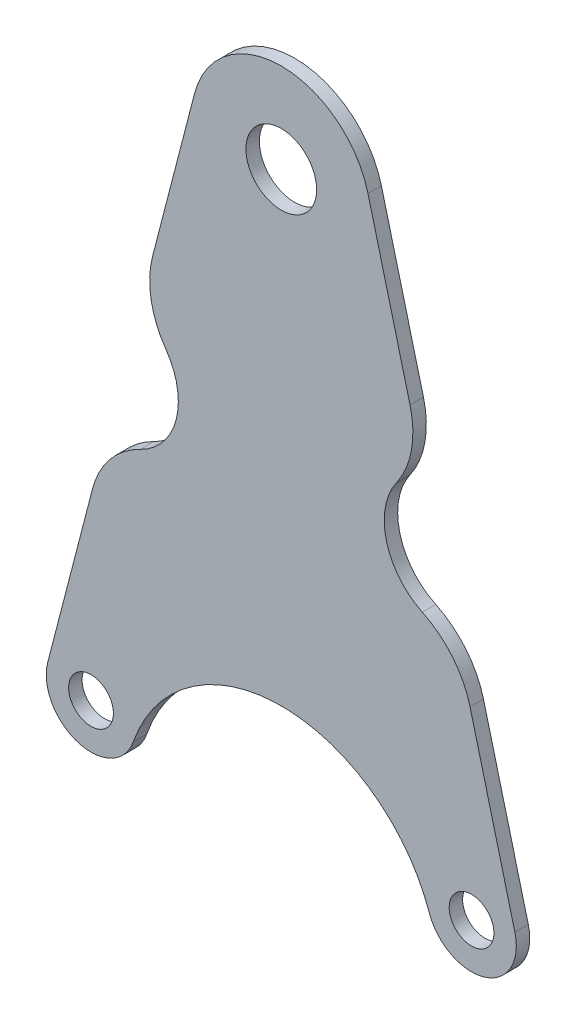
from build123d import *

# Parameters (mm, degrees)
SKETCH_1_R          = 7.9
SKETCH_1_R_2        = 5
EXTRUDE_1_DEPTH     = 3
SKETCH_3_R          = 15
CUT_EXTRUDE_2_DEPTH = 4
FILLET_1_R          = 20


with BuildPart() as part:
    # Эскиз1 → Бобышка-Вытянуть1 (new body)
    with BuildSketch(Plane.XY):
        with BuildLine():
            Line((-19.359148134, 5.022288675), (-52.179574067, -121.488855663))
            ThreePointArc((-52.179574067, -121.488855663), (-45.401310581, -133.569869221), (-33.055555556, -127.286710991))
            ThreePointArc((-33.055555556, -127.286710991), (0, -103.790199458), (33.055555556, -127.286710991))
            ThreePointArc((33.055555556, -127.286710991), (45.401310581, -133.569869221), (52.179574067, -121.488855663))
            Line((52.179574067, -121.488855663), (19.359148134, 5.022288675))
            ThreePointArc((19.359148134, 5.022288675), (0, 20), (-19.359148134, 5.022288675))
        make_face()
        Circle(SKETCH_1_R, mode=Mode.SUBTRACT)
        with Locations((-42.5, -124)):
            Circle(SKETCH_1_R_2, mode=Mode.SUBTRACT)
        with Locations((42.5, -124)):
            Circle(SKETCH_1_R_2, mode=Mode.SUBTRACT)
    extrude(amount=EXTRUDE_1_DEPTH)

    # Эскиз3 → Вырез-Вытянуть2 (cut, through all)
    with BuildSketch(Plane.XY.offset(3)):
        with Locations((-38, -56.391488719)):
            Circle(SKETCH_3_R)
        with Locations((38, -56.391488719)):
            Circle(SKETCH_3_R)
    extrude(amount=-CUT_EXTRUDE_2_DEPTH, mode=Mode.SUBTRACT)

    # Скругление1
    fillet_1_edges = [part.edges().sort_by_distance(p)[0] for p in [
        (-39.171079178, -71.345704632, 1.5),
        (-31.7536013, -42.753948498, 1.5),
        (31.7536013, -42.753948498, 1.5),
        (39.171079178, -71.345704632, 1.5),
    ]]
    fillet(fillet_1_edges, radius=FILLET_1_R)


solid = part.part
